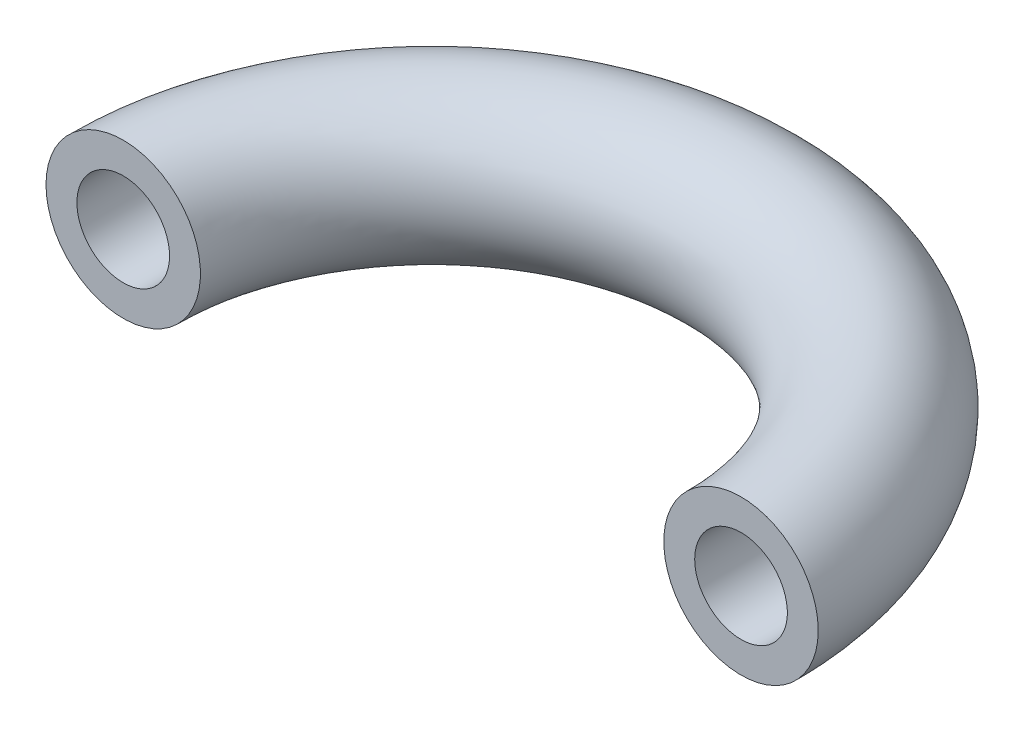
from build123d import *

# Parameters (mm, degrees)
SWEEP1_PROFILE_R   = 2.5
SKETCH14_R         = 1.5
CUT_EXTRUDE1_DEPTH = 4


with BuildPart() as part:
    # Sweep1: sweep along a path in Sketch1
    with BuildLine(Plane(origin=(0, 0, 0), x_dir=(1, 0, 0), z_dir=(0, 1, 0))) as sweep1_path:
        ThreePointArc((-10, 0), (0, 10), (10, 0))
    # Sweep1 profile (on start of the path) → Sweep1 (sweep)
    with BuildSketch(Plane(origin=(-10, 0, 0), x_dir=(-1, 0, 0), z_dir=(0, 0, -1))):
        Circle(SWEEP1_PROFILE_R)
    sweep(path=sweep1_path.line)

    # Sketch14 → Cut-Extrude1 (cut)
    with BuildSketch(Plane.XY):
        with Locations((-10, 0)):
            Circle(SKETCH14_R)
    cut_extrude1 = extrude(amount=-CUT_EXTRUDE1_DEPTH, mode=Mode.SUBTRACT)

    # Mirror1: Cut-Extrude1 across plane
    add(cut_extrude1.mirror(Plane(origin=(0, 0, 0), x_dir=(0, 0, 1), z_dir=(1, 0, 0))), mode=Mode.SUBTRACT)


solid = part.part
